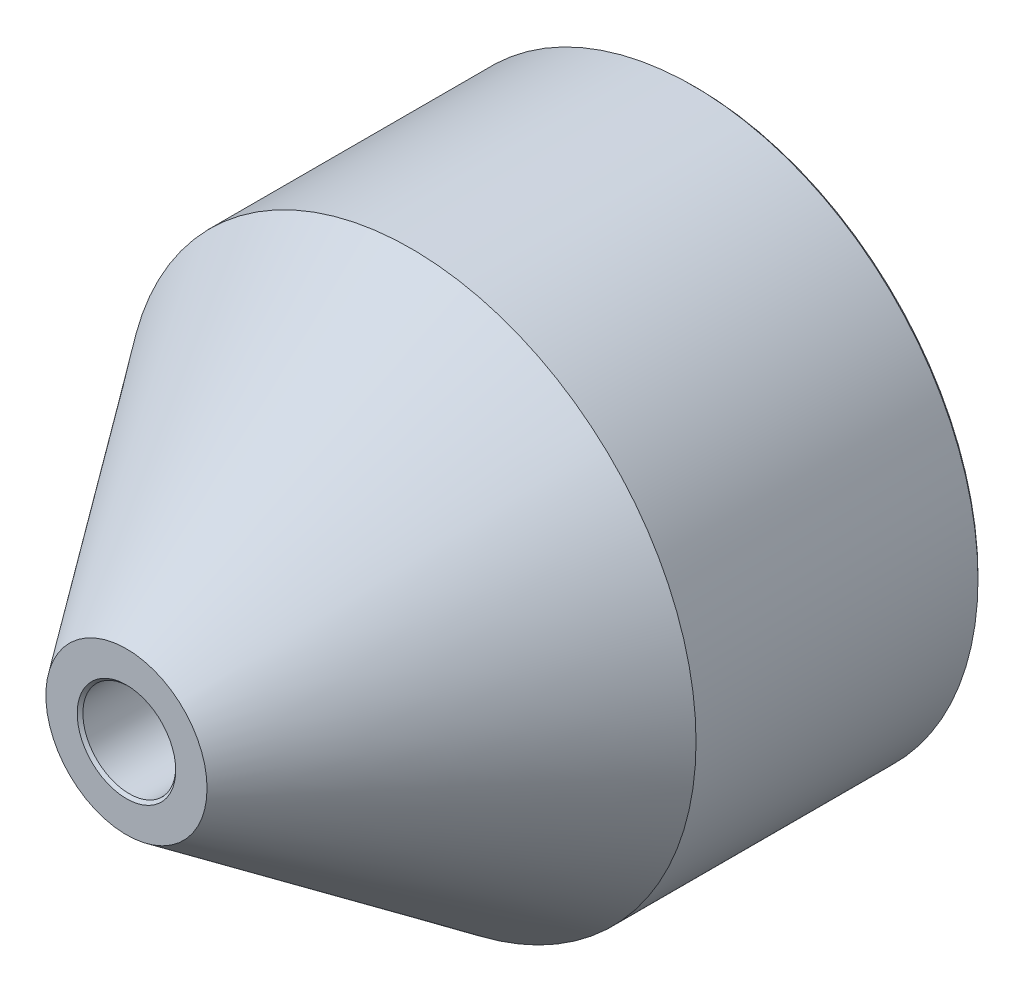
from build123d import *

# Parameters (mm, degrees)
CHAMFER1_SIZE = 0.5


with BuildPart() as part:
    # Sketch1 → Revolve1 (revolve)
    with BuildSketch(Plane(origin=(0, 0, 0), x_dir=(1, 0, 0), z_dir=(0, 1, 0))):
        Polygon((0, 27.73647874), (4.15, 27.73647874), (4.15, 37.73647874), (50, 37.73647874), (50, -12.26352126), (14.15, -62.26352126), (8.15, -62.26352126), (8.15, -12.26352126), (0, -12.26352126), align=None)
    revolve(axis=Axis((0, 0, 12.26352126), (0, 0, -1)))

    # Chamfer1
    chamfer1_edges = [part.edges().sort_by_distance(p)[0] for p in [
        (-8.15, 0, 62.26352126),
        (-50, 0, -37.73647874),
        (-4.15, 0, -37.73647874),
    ]]
    chamfer(chamfer1_edges, length=CHAMFER1_SIZE)


solid = part.part
